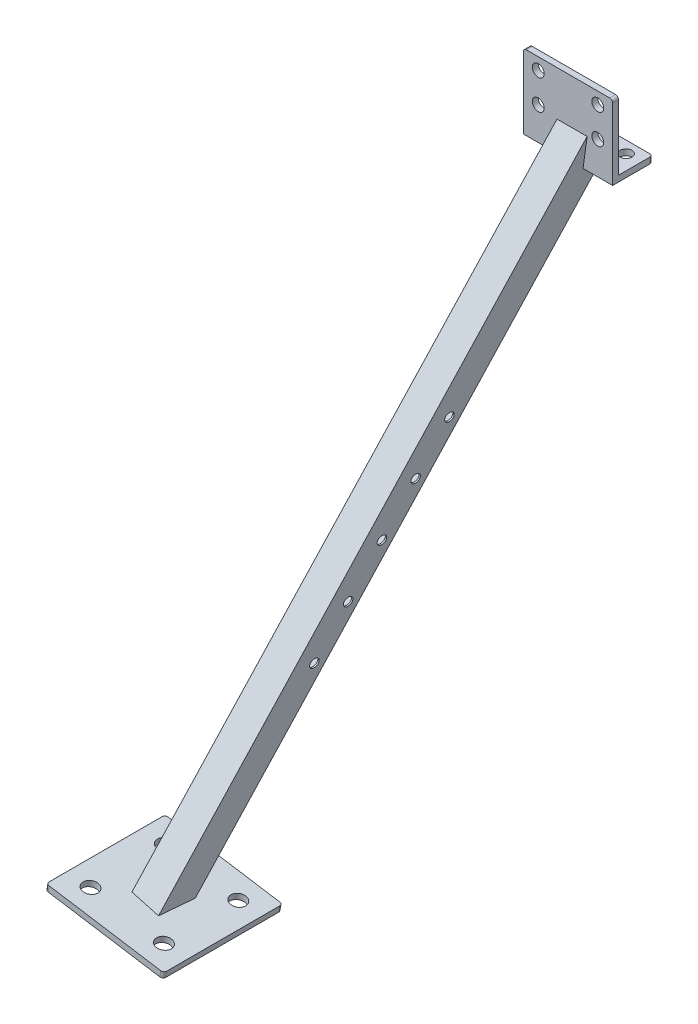
from build123d import *

# Parameters (mm, degrees)
BOSS_EXTRUDE1_DEPTH      = 60
SKETCH3_W                = 20
SKETCH3_H                = 20
SKETCH3_W_2              = 18
SKETCH3_H_2              = 18
BOSS_EXTRUDE2_DEPTH      = 500
BOSS_EXTRUDE2_DEPTH_BACK = 20
CUT_EXTRUDE1_DEPTH       = 60
SKETCH6_W                = 80
SKETCH6_H                = 80
BOSS_EXTRUDE3_DEPTH      = 4
SKETCH7_W                = 66.533073227
SKETCH7_H                = 100
CUT_EXTRUDE2_DEPTH       = 100
CUT_EXTRUDE3_REACH       = 29
SKETCH8_R                = 3.999999996
CUT_EXTRUDE4_REACH       = 52
SKETCH9_R                = 4.000000003
CUT_EXTRUDE5_REACH       = 423.587
SKETCH10_R               = 5
FILLET1_R                = 2
FILLET2_R                = 2
SKETCH11_RX              = 3
SKETCH11_RY              = 2.990164225
CUT_EXTRUDE6_DEPTH       = 109.672499864


with BuildPart() as part:
    # Sketch1 → Boss-Extrude1 (new body)
    with BuildSketch(Plane(origin=(0, 0, 0), x_dir=(0, 0, -1), z_dir=(1, 0, 0))):
        Polygon((0, 0), (0, 50), (4, 50), (4, 4), (27, 4), (27, 0), align=None)
    extrude(amount=BOSS_EXTRUDE1_DEPTH)

    # Sketch3 → Boss-Extrude2 (add, two sides)
    with BuildSketch(Plane(origin=(0.734152256, 4.01424851, -2.317627458), x_dir=(0, -0.5, -0.866025404), z_dir=(-0.156434465, -0.855363194, 0.49384417))) as boss_extrude2_sk:
        with Locations((0, 29.630650218)):
            Rectangle(SKETCH3_W, SKETCH3_H)
        with Locations((0, 29.630650218)):
            Rectangle(SKETCH3_W_2, SKETCH3_H_2, mode=Mode.SUBTRACT)
    extrude(amount=BOSS_EXTRUDE2_DEPTH)
    extrude(boss_extrude2_sk.sketch, amount=-BOSS_EXTRUDE2_DEPTH_BACK)

    # Sketch4 → Cut-Extrude1 (cut)
    with BuildSketch(Plane.ZY):
        Polygon((-4, 4), (-4, 34.425897354), (-31.384039134, 4), align=None)
    extrude(amount=-CUT_EXTRUDE1_DEPTH, mode=Mode.SUBTRACT)

    # Sketch6 → Boss-Extrude3 (add)
    with BuildSketch(Plane(origin=(-56.756977587, -358.349449027, -6.04e-07), x_dir=(0.98768834, -0.156434467, 0), z_dir=(0.156434467, 0.98768834, 2e-09))):
        with Locations((20.602499347, -205.593740339)):
            Rectangle(SKETCH6_W, SKETCH6_H)
    extrude(amount=BOSS_EXTRUDE3_DEPTH)

    # Sketch7 → Cut-Extrude2 (cut)
    with BuildSketch(Plane(origin=(-56.756977587, -358.349449027, -6.04e-07), x_dir=(0.98768834, -0.156434467, 0), z_dir=(-0.156434467, -0.98768834, -2e-09))):
        with Locations((19.03398873, 218.773795259)):
            Rectangle(SKETCH7_W, SKETCH7_H)
    extrude(amount=CUT_EXTRUDE2_DEPTH, mode=Mode.SUBTRACT)

    # Sketch8 → Cut-Extrude3 (cut, up to next)
    with BuildSketch(Plane.XY, mode=Mode.PRIVATE) as cut_extrude3_sk1:
        with Locations((10, 22)):
            Circle(SKETCH8_R)
    cut_extrude3_tool1 = extrude(cut_extrude3_sk1.sketch, amount=-CUT_EXTRUDE3_REACH, mode=Mode.PRIVATE) & part.part
    add(cut_extrude3_tool1.solids().sort_by_distance((10, 22, 0))[0], mode=Mode.SUBTRACT)
    # Sketch8 → Cut-Extrude3 (cut, up to next)
    with BuildSketch(Plane.XY, mode=Mode.PRIVATE) as cut_extrude3_sk2:
        with Locations((50, 22)):
            Circle(SKETCH8_R)
    cut_extrude3_tool2 = extrude(cut_extrude3_sk2.sketch, amount=-CUT_EXTRUDE3_REACH, mode=Mode.PRIVATE) & part.part
    add(cut_extrude3_tool2.solids().sort_by_distance((50, 22, 0))[0], mode=Mode.SUBTRACT)
    # Sketch8 → Cut-Extrude3 (cut, up to next)
    with BuildSketch(Plane.XY, mode=Mode.PRIVATE) as cut_extrude3_sk3:
        with Locations((50, 42)):
            Circle(SKETCH8_R)
    cut_extrude3_tool3 = extrude(cut_extrude3_sk3.sketch, amount=-CUT_EXTRUDE3_REACH, mode=Mode.PRIVATE) & part.part
    add(cut_extrude3_tool3.solids().sort_by_distance((50, 42, 0))[0], mode=Mode.SUBTRACT)
    # Sketch8 → Cut-Extrude3 (cut, up to next)
    with BuildSketch(Plane.XY, mode=Mode.PRIVATE) as cut_extrude3_sk4:
        with Locations((10, 42)):
            Circle(SKETCH8_R)
    cut_extrude3_tool4 = extrude(cut_extrude3_sk4.sketch, amount=-CUT_EXTRUDE3_REACH, mode=Mode.PRIVATE) & part.part
    add(cut_extrude3_tool4.solids().sort_by_distance((10, 42, 0))[0], mode=Mode.SUBTRACT)

    # Sketch9 → Cut-Extrude4 (cut, up to next)
    with BuildSketch(Plane.XZ, mode=Mode.PRIVATE) as cut_extrude4_sk1:
        with Locations((50, -19)):
            Circle(SKETCH9_R)
    cut_extrude4_tool1 = extrude(cut_extrude4_sk1.sketch, amount=-CUT_EXTRUDE4_REACH, mode=Mode.PRIVATE) & part.part
    add(cut_extrude4_tool1.solids().sort_by_distance((50, 0, -19))[0], mode=Mode.SUBTRACT)
    # Sketch9 → Cut-Extrude4 (cut, up to next)
    with BuildSketch(Plane.XZ, mode=Mode.PRIVATE) as cut_extrude4_sk2:
        with Locations((10, -19)):
            Circle(SKETCH9_R)
    cut_extrude4_tool2 = extrude(cut_extrude4_sk2.sketch, amount=-CUT_EXTRUDE4_REACH, mode=Mode.PRIVATE) & part.part
    add(cut_extrude4_tool2.solids().sort_by_distance((10, 0, -19))[0], mode=Mode.SUBTRACT)

    # Sketch10 → Cut-Extrude5 (cut, up to next)
    with BuildSketch(Plane(origin=(-56.756977587, -358.349449027, -6.04e-07), x_dir=(0.98768834, -0.156434467, 0), z_dir=(-0.156434467, -0.98768834, -2e-09)), mode=Mode.PRIVATE) as cut_extrude5_sk1:
        with Locations((-4.397500653, 230.593740339)):
            Circle(SKETCH10_R)
    cut_extrude5_tool1 = extrude(cut_extrude5_sk1.sketch, amount=-CUT_EXTRUDE5_REACH, mode=Mode.PRIVATE) & part.part
    add(cut_extrude5_tool1.solids().sort_by_distance((-61.100338, -357.661529, 230.59374))[0], mode=Mode.SUBTRACT)
    # Sketch10 → Cut-Extrude5 (cut, up to next)
    with BuildSketch(Plane(origin=(-56.756977587, -358.349449027, -6.04e-07), x_dir=(0.98768834, -0.156434467, 0), z_dir=(-0.156434467, -0.98768834, -2e-09)), mode=Mode.PRIVATE) as cut_extrude5_sk2:
        with Locations((45.602499347, 230.593740339)):
            Circle(SKETCH10_R)
    cut_extrude5_tool2 = extrude(cut_extrude5_sk2.sketch, amount=-CUT_EXTRUDE5_REACH, mode=Mode.PRIVATE) & part.part
    add(cut_extrude5_tool2.solids().sort_by_distance((-11.715921, -365.483252, 230.59374))[0], mode=Mode.SUBTRACT)
    # Sketch10 → Cut-Extrude5 (cut, up to next)
    with BuildSketch(Plane(origin=(-56.756977587, -358.349449027, -6.04e-07), x_dir=(0.98768834, -0.156434467, 0), z_dir=(-0.156434467, -0.98768834, -2e-09)), mode=Mode.PRIVATE) as cut_extrude5_sk3:
        with Locations((45.602499347, 180.593740339)):
            Circle(SKETCH10_R)
    cut_extrude5_tool3 = extrude(cut_extrude5_sk3.sketch, amount=-CUT_EXTRUDE5_REACH, mode=Mode.PRIVATE) & part.part
    add(cut_extrude5_tool3.solids().sort_by_distance((-11.715921, -365.483252, 180.59374))[0], mode=Mode.SUBTRACT)
    # Sketch10 → Cut-Extrude5 (cut, up to next)
    with BuildSketch(Plane(origin=(-56.756977587, -358.349449027, -6.04e-07), x_dir=(0.98768834, -0.156434467, 0), z_dir=(-0.156434467, -0.98768834, -2e-09)), mode=Mode.PRIVATE) as cut_extrude5_sk4:
        with Locations((-4.397500653, 180.593740339)):
            Circle(SKETCH10_R)
    cut_extrude5_tool4 = extrude(cut_extrude5_sk4.sketch, amount=-CUT_EXTRUDE5_REACH, mode=Mode.PRIVATE) & part.part
    add(cut_extrude5_tool4.solids().sort_by_distance((-61.100338, -357.661529, 180.59374))[0], mode=Mode.SUBTRACT)

    # Fillet1
    fillet1_edges = [part.edges().sort_by_distance(p)[0] for p in [
        (-75.602793879, -353.339634953, 165.593739744),
        (-75.602793879, -353.339635088, 245.593739744),
        (3.412273346, -365.854392434, 245.593739723),
        (3.412273346, -365.854392299, 165.593739723),
    ]]
    fillet(fillet1_edges, radius=FILLET1_R)

    # Fillet2
    fillet2_edges = [part.edges().sort_by_distance(p)[0] for p in [
        (60, 50, -2),
        (0, 50, -2),
        (60, 2, -27),
        (0, 2, -27),
    ]]
    fillet(fillet2_edges, radius=FILLET2_R)

    # Sketch11 → Cut-Extrude6 (cut, through all)
    with BuildSketch(Plane(origin=(19.388964338, -2.659486302, 1.535455133), x_dir=(-0.077491657, 0.010629139, 0.996936339), z_dir=(-0.987688341, 0.135476221, -0.078217233))):
        with Locations(Location((133.973315354, -240.089665543), (0, 0, -75.129892221))):
            Ellipse(SKETCH11_RX, SKETCH11_RY)
        with Locations(Location((116.692587924, -209.661795411), (0, 0, -75.129892221))):
            Ellipse(SKETCH11_RX, SKETCH11_RY)
        with Locations(Location((99.411860493, -179.23392528), (0, 0, -75.129892221))):
            Ellipse(SKETCH11_RX, SKETCH11_RY)
        with Locations(Location((82.131133063, -148.806055148), (0, 0, -75.129892221))):
            Ellipse(SKETCH11_RX, SKETCH11_RY)
        with Locations(Location((64.850405632, -118.378185017), (0, 0, -75.129892221))):
            Ellipse(SKETCH11_RX, SKETCH11_RY)
    extrude(amount=-CUT_EXTRUDE6_DEPTH, mode=Mode.SUBTRACT)


solid = part.part
